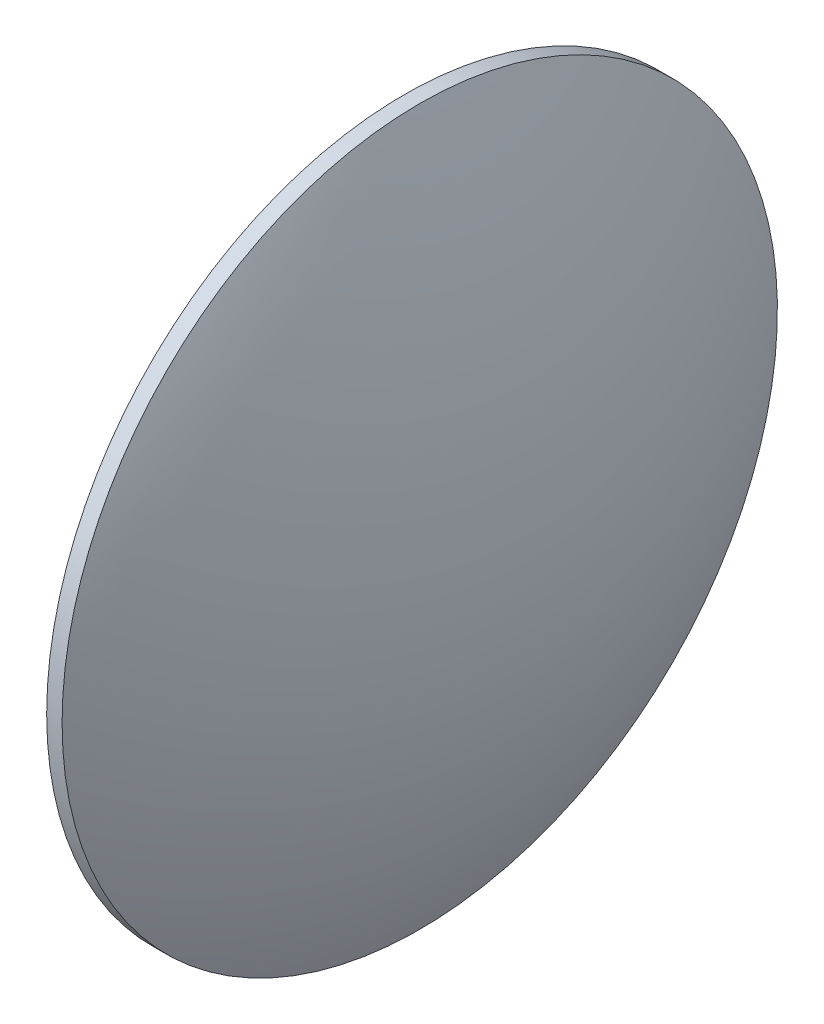
from build123d import *


with BuildPart() as part:
    # 草图1 → 旋转1 (revolve)
    with BuildSketch(Plane.XY):
        with BuildLine():
            Line((548.51914828, 55.907975843), (548.51914828, 78.407975843))
            Line((548.51914828, 78.407975843), (549.48914828, 78.407975843))
            ThreePointArc((549.48914828, 78.407975843), (553.320400546, 67.44668136), (554.61914828, 55.907975843))
            Line((554.61914828, 55.907975843), (548.51914828, 55.907975843))
        make_face()
    revolve(axis=Axis((543.870940653, 55.907975843, 0), (1, 0, 0)))


solid = part.part
